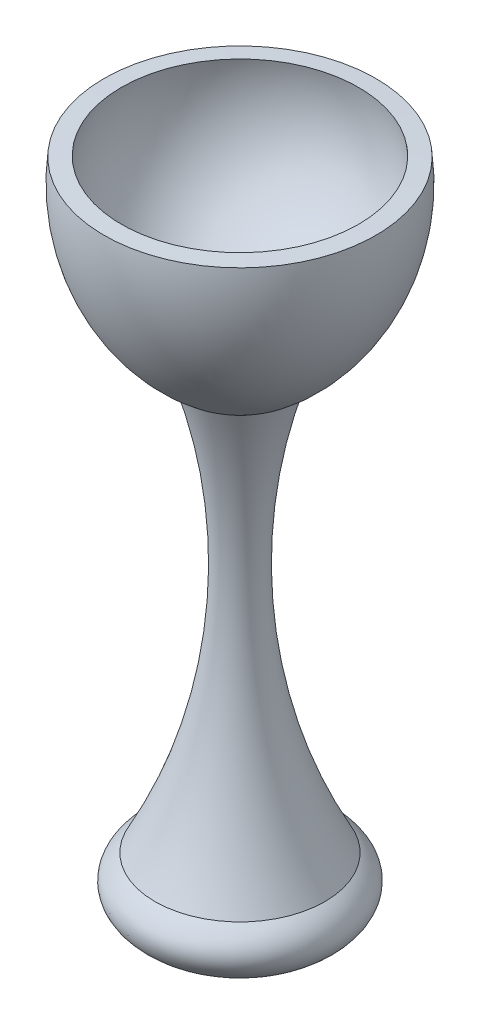
from build123d import *


with BuildPart() as part:
    # Sketch1 → Revolve1 (revolve)
    with BuildSketch(Plane.XY):
        with BuildLine():
            Line((0, -50.8), (0, -273.05))
            add(Edge.make_bspline(
                [(0, -273.05), (76.928972676, -273.05), (35.706992461, -243.792158978)],
                knots=[1.570796327, 1.570796327, 1.570796327, 3.707100506, 3.707100506, 3.707100506], degree=2, weights=[1, 0.481744396, 1]))
            ThreePointArc((35.706992461, -243.792158978), (10.264506747, -158.831939986), (19.86512656, -70.66512656))
            ThreePointArc((19.86512656, -70.66512656), (49.752179365, -35.880227818), (57.11468125, 9.38585962))
            Line((57.11468125, 9.38585962), (49.851566375, 9.770431413))
            ThreePointArc((49.851566375, 9.770431413), (47.926617328, -16.842783365), (32.779270712, -38.809269661))
            ThreePointArc((32.779270712, -38.809269661), (17.451777864, -47.708232512), (0, -50.8))
        make_face()
    revolve(axis=Axis((0, -50.8, 0), (0, -1, 0)))


solid = part.part
